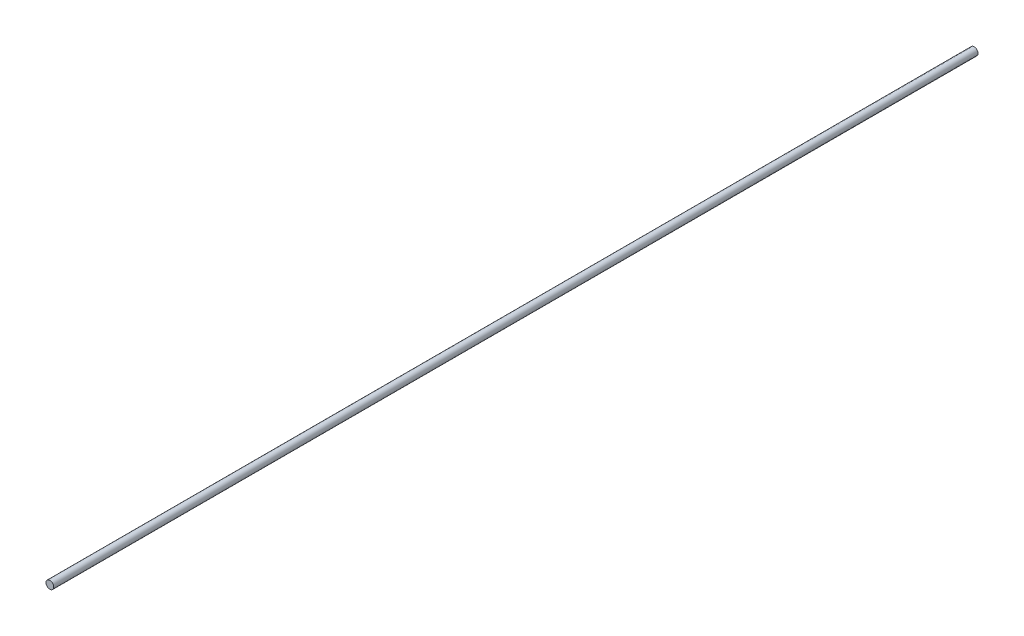
from build123d import *

# Parameters (mm, degrees)
SKETCH1_R           = 3.175
BOSS_EXTRUDE1_DEPTH = 762


with BuildPart() as part:
    # Sketch1 → Boss-Extrude1 (new body)
    with BuildSketch(Plane.XY):
        Circle(SKETCH1_R)
    extrude(amount=BOSS_EXTRUDE1_DEPTH)


solid = part.part
